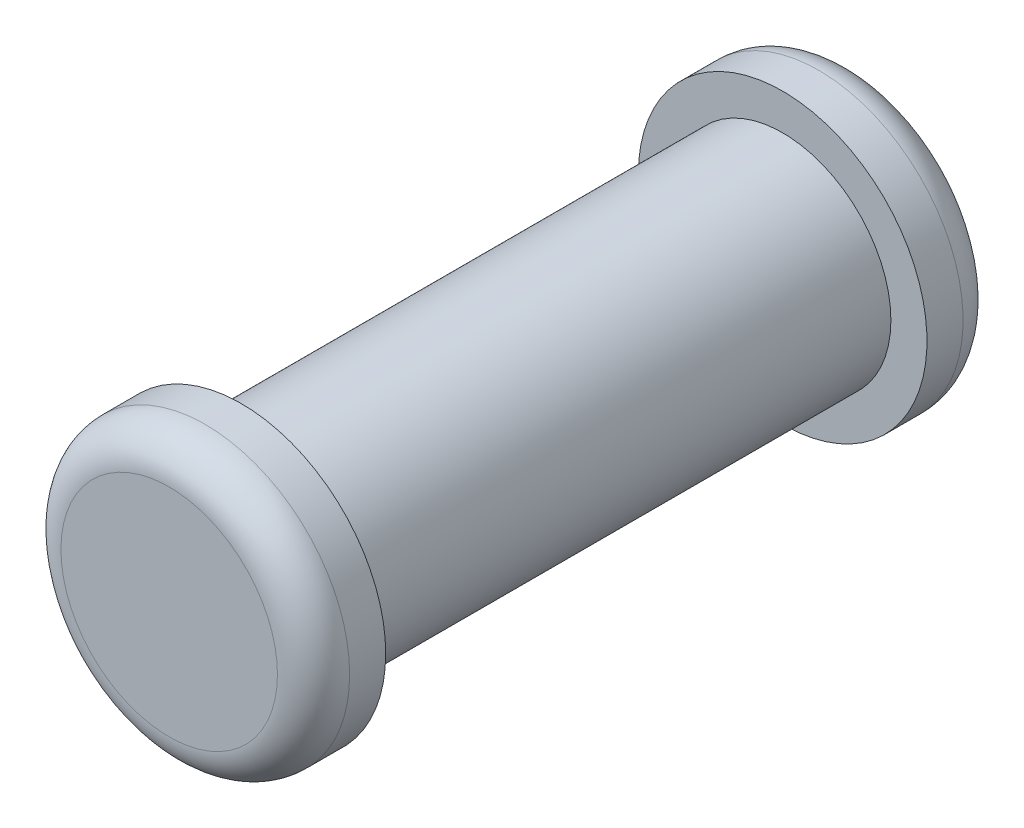
from build123d import *

# Parameters (mm, degrees)
SKETCH1_R           = 1.5
BOSS_EXTRUDE1_DEPTH = 7.5
SKETCH2_R           = 2
BOSS_EXTRUDE2_DEPTH = 1
SKETCH3_R           = 2
BOSS_EXTRUDE3_DEPTH = 1
FILLET1_R           = 0.5


with BuildPart() as part:
    # Sketch1 → Boss-Extrude1 (new body)
    with BuildSketch(Plane.XY):
        Circle(SKETCH1_R)
    extrude(amount=BOSS_EXTRUDE1_DEPTH)

    # Sketch2 → Boss-Extrude2 (add)
    with BuildSketch(Plane(origin=(0, 0, 0), x_dir=(-1, 0, 0), z_dir=(0, 0, -1))):
        Circle(SKETCH2_R)
    extrude(amount=BOSS_EXTRUDE2_DEPTH)

    # Sketch3 → Boss-Extrude3 (add)
    with BuildSketch(Plane.XY.offset(7.5)):
        Circle(SKETCH3_R)
    extrude(amount=BOSS_EXTRUDE3_DEPTH)

    # Fillet1
    fillet1_edges = [part.edges().sort_by_distance(p)[0] for p in [
        (-2, 0, 8.5),
        (2, 0, -1),
    ]]
    fillet(fillet1_edges, radius=FILLET1_R)


solid = part.part
